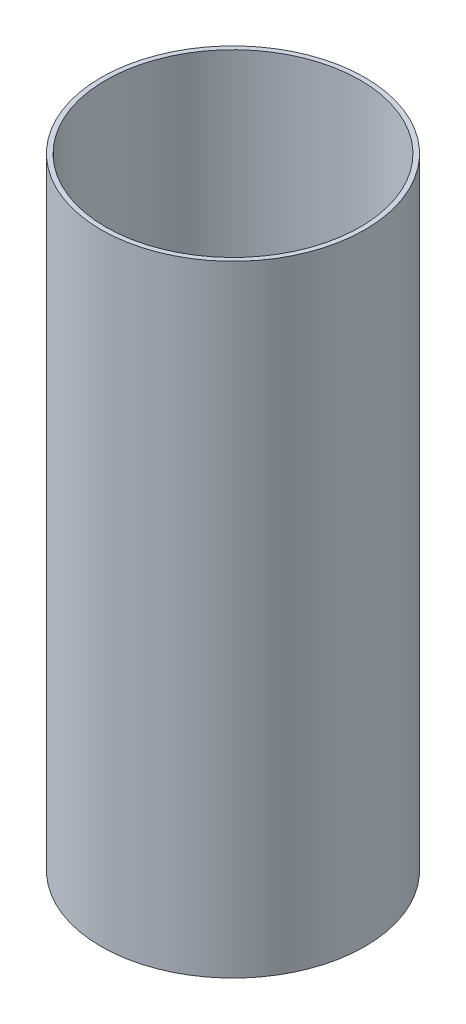
from build123d import *

# Parameters (mm, degrees)
SKETCH1_R           = 42.5
SKETCH1_R_2         = 41
BOSS_EXTRUDE1_DEPTH = 200


with BuildPart() as part:
    # Sketch1 → Boss-Extrude1 (new body)
    with BuildSketch(Plane(origin=(0, 0, 0), x_dir=(1, 0, 0), z_dir=(0, 1, 0))):
        Circle(SKETCH1_R)
        Circle(SKETCH1_R_2, mode=Mode.SUBTRACT)
    extrude(amount=BOSS_EXTRUDE1_DEPTH)


solid = part.part
